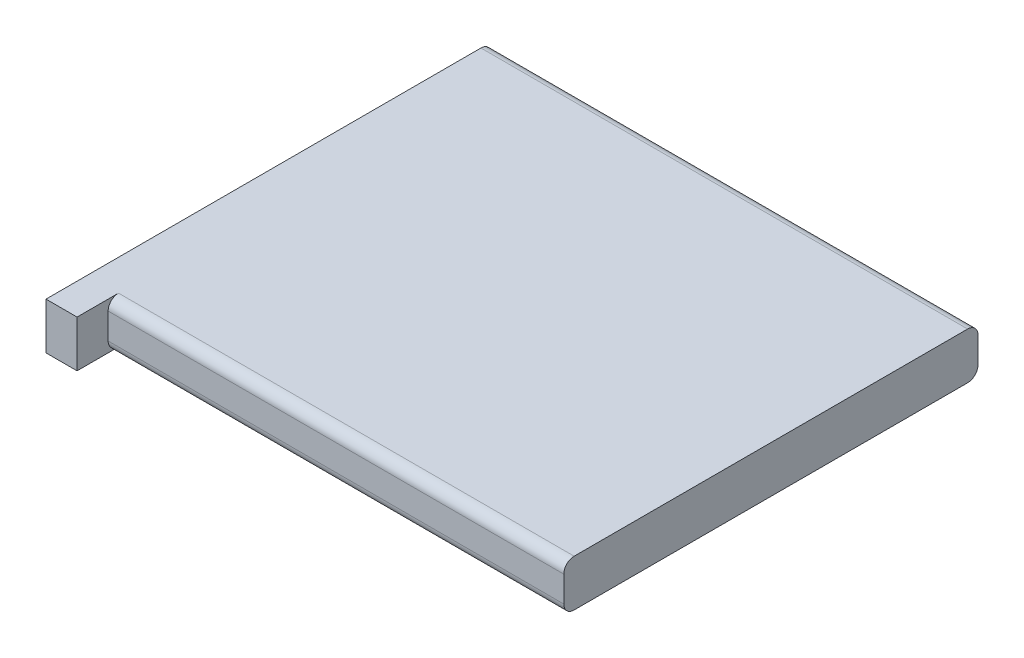
from build123d import *

# Parameters (mm, degrees)
SKETCH1_W                = 47
SKETCH1_H                = 40
BOSS_EXTRUDE1_DEPTH      = 4.5
FILLET1_R                = 1
SKETCH2_W                = 3
SKETCH2_H                = 4.5
BOSS_EXTRUDE2_DEPTH      = 3
BOSS_EXTRUDE2_DEPTH_BACK = 3


with BuildPart() as part:
    # Sketch1 → Boss-Extrude1 (new body)
    with BuildSketch(Plane(origin=(0, 0, 0), x_dir=(1, 0, 0), z_dir=(0, 1, 0))):
        Rectangle(SKETCH1_W, SKETCH1_H)
    extrude(amount=BOSS_EXTRUDE1_DEPTH)

    # Fillet1
    fillet1_edges = [part.edges().sort_by_distance(p)[0] for p in [
        (0, 4.5, -20),
        (0, 0, -20),
        (0, 0, 20),
        (0, 4.5, 20),
    ]]
    fillet(fillet1_edges, radius=FILLET1_R)

    # Sketch2 → Boss-Extrude2 (add, two sides)
    with BuildSketch(Plane.XY.offset(20)) as boss_extrude2_sk:
        with Locations((-22, 2.25)):
            Rectangle(SKETCH2_W, SKETCH2_H)
    extrude(amount=BOSS_EXTRUDE2_DEPTH)
    extrude(boss_extrude2_sk.sketch, amount=-BOSS_EXTRUDE2_DEPTH_BACK)


solid = part.part
